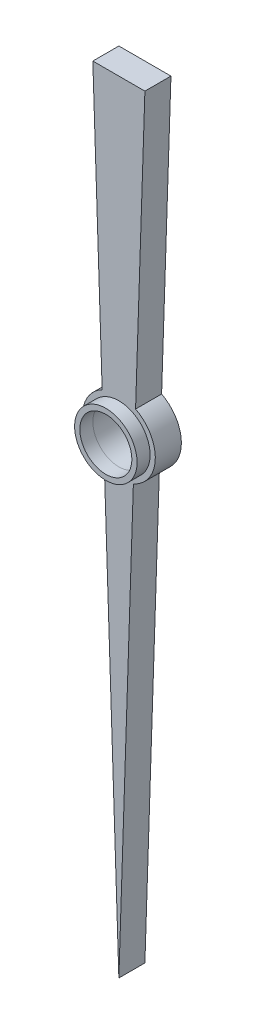
from build123d import *

# Parameters (mm, degrees)
ESBO_O1_R                = 1
RESSALTO_EXTRUS_O1_DEPTH = 1
ESBO_O3_R                = 1.2
ESBO_O3_R_2              = 0.999056936
RESSALTO_EXTRUS_O2_DEPTH = 0.5


with BuildPart() as part:
    # Esboço1 → Ressalto-extrusão1 (new body)
    with BuildSketch(Plane.XY):
        with BuildLine():
            Line((0, 30), (1, 30))
            Line((1, 30), (0.641479632, 19.244388959))
            ThreePointArc((0.641479632, 19.244388959), (1.39922287, 17.953359238), (0.557188515, 16.715655436))
            Line((0.557188515, 16.715655436), (0, 0))
            Line((0, 0), (-0.557188515, 16.715655436))
            ThreePointArc((-0.557188515, 16.715655436), (-1.39922287, 17.953359238), (-0.641479632, 19.244388959))
            Line((-0.641479632, 19.244388959), (-1, 30))
            Line((-1, 30), (0, 30))
        make_face()
        with Locations((0, 18)):
            Circle(ESBO_O1_R, mode=Mode.SUBTRACT)
    extrude(amount=RESSALTO_EXTRUS_O1_DEPTH)

    # Esboço3 → Ressalto-extrusão2 (add)
    with BuildSketch(Plane.XY.offset(1)):
        with Locations((0, 18)):
            Circle(ESBO_O3_R)
        with Locations((0, 18)):
            Circle(ESBO_O3_R_2, mode=Mode.SUBTRACT)
    extrude(amount=RESSALTO_EXTRUS_O2_DEPTH)


solid = part.part
